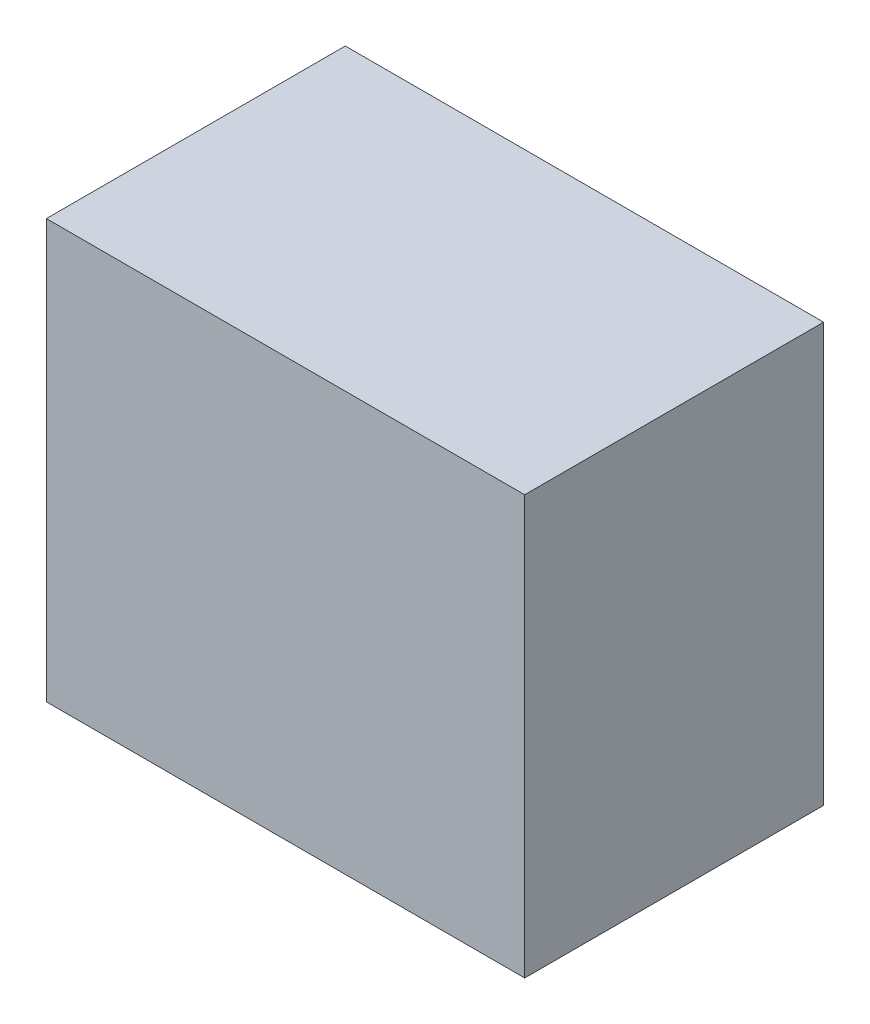
from build123d import *

# Parameters (mm, degrees)
SKETCH_1_W      = 80
SKETCH_1_H      = 70
EXTRUDE_1_DEPTH = 25


with BuildPart() as part:
    # Эскиз1 → Бобышка-Вытянуть1 (new body, symmetric)
    with BuildSketch(Plane.XY):
        Rectangle(SKETCH_1_W, SKETCH_1_H)
    extrude(amount=EXTRUDE_1_DEPTH, both=True)


solid = part.part
